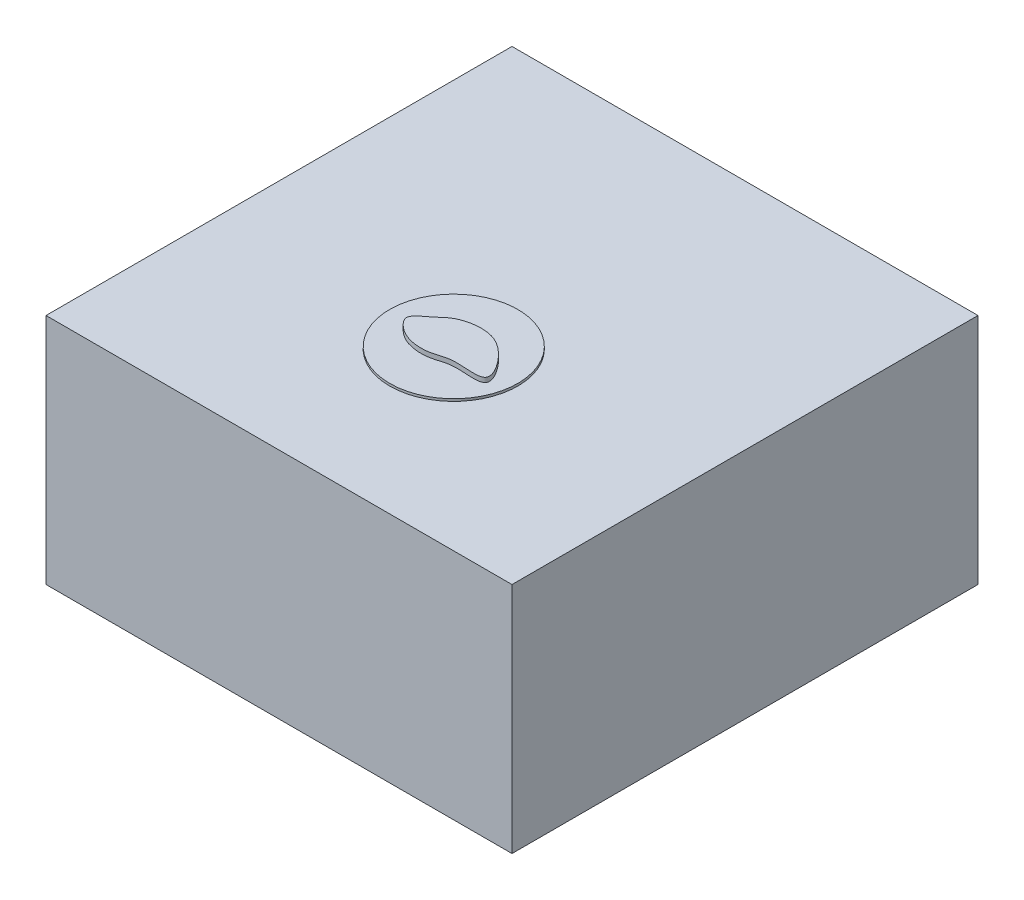
from build123d import *

# Parameters (mm, degrees)
SKETCH1_W             = 20
SKETCH1_H             = 10
BOSS_EXTRUDE1_DEPTH   = 20
SKETCH2_R             = 0.5
SKETCH5_R             = 2.75
BOSS_EXTRUDE4_DEPTH   = 0.1
SKETCH8_R             = 0.005
BOSS_EXTRUDE5_DEPTH   = 0.1
BOSS_EXTRUDE5_2_DEPTH = 0.1
BOSS_EXTRUDE5_3_DEPTH = 0.1
BOSS_EXTRUDE5_4_DEPTH = 0.1
BOSS_EXTRUDE5_5_DEPTH = 0.1
BOSS_EXTRUDE5_6_DEPTH = 0.1
BOSS_EXTRUDE5_7_DEPTH = 0.1
BOSS_EXTRUDE5_8_DEPTH = 0.1
BOSS_EXTRUDE5_9_DEPTH = 0.1
SLICE_2_DEPTH         = 0.3


with BuildPart() as part:
    # Sketch1 → Boss-Extrude1 (new body)
    with BuildSketch(Plane.XY):
        Rectangle(SKETCH1_W, SKETCH1_H)
    extrude(amount=BOSS_EXTRUDE1_DEPTH)


with BuildPart() as body_2:
    # ag/agcl electrodes: sweep along a path in Sketch3
    with BuildLine(Plane(origin=(7.5, 0, 0), x_dir=(0, 0, -1), z_dir=(1, 0, 0))) as ag_agcl_electrodes_path:
        Line((-20, 4), (-5, 4))
        ThreePointArc((-5, 4), (-4.292893219, 4.292893219), (-4, 5))
    # Sketch2 → ag/agcl electrodes (sweep)
    with BuildSketch(Plane.XY.offset(20)):
        with Locations((-7.5, 4)):
            Circle(SKETCH2_R)
        with Locations((7.5, 4)):
            Circle(SKETCH2_R)
    sweep(path=ag_agcl_electrodes_path.line)


with BuildPart() as body_3:
    # Sketch5 → Boss-Extrude4 (new body)
    with BuildSketch(Plane(origin=(0, 5, 0), x_dir=(1, 0, 0), z_dir=(0, 1, 0))):
        with Locations(Location((0, -12.5, 0), (0, 0, 270))):
            Circle(SKETCH5_R)
    extrude(amount=BOSS_EXTRUDE4_DEPTH)


with BuildPart() as body_4:
    # Sketch8 → Boss-Extrude5 (new body)
    with BuildSketch(Plane(origin=(0, 5.1, 0), x_dir=(-1, 0, 0), z_dir=(0, -1, 0))):
        with Locations(Location((0, -12.5, 0), (0, 0, 90))):
            Circle(SKETCH8_R)
    extrude(amount=BOSS_EXTRUDE5_DEPTH)


with BuildPart() as body_5:
    # Sketch8 → Boss-Extrude5 2 (new body)
    with BuildSketch(Plane(origin=(0, 5.1, 0), x_dir=(-1, 0, 0), z_dir=(0, -1, 0))):
        with Locations(Location((0.5, -12.5, 0), (0, 0, 90))):
            Circle(SKETCH8_R)
    extrude(amount=BOSS_EXTRUDE5_2_DEPTH)


with BuildPart() as body_6:
    # Sketch8 → Boss-Extrude5 3 (new body)
    with BuildSketch(Plane(origin=(0, 5.1, 0), x_dir=(-1, 0, 0), z_dir=(0, -1, 0))):
        with Locations(Location((0.5, -12, 0), (0, 0, 90))):
            Circle(SKETCH8_R)
    extrude(amount=BOSS_EXTRUDE5_3_DEPTH)


with BuildPart() as body_7:
    # Sketch8 → Boss-Extrude5 4 (new body)
    with BuildSketch(Plane(origin=(0, 5.1, 0), x_dir=(-1, 0, 0), z_dir=(0, -1, 0))):
        with Locations(Location((0, -12, 0), (0, 0, 90))):
            Circle(SKETCH8_R)
    extrude(amount=BOSS_EXTRUDE5_4_DEPTH)


with BuildPart() as body_8:
    # Sketch8 → Boss-Extrude5 5 (new body)
    with BuildSketch(Plane(origin=(0, 5.1, 0), x_dir=(-1, 0, 0), z_dir=(0, -1, 0))):
        with Locations(Location((0.5, -13, 0), (0, 0, 270))):
            Circle(SKETCH8_R)
    extrude(amount=BOSS_EXTRUDE5_5_DEPTH)


with BuildPart() as body_9:
    # Sketch8 → Boss-Extrude5 6 (new body)
    with BuildSketch(Plane(origin=(0, 5.1, 0), x_dir=(-1, 0, 0), z_dir=(0, -1, 0))):
        with Locations(Location((0, -13, 0), (0, 0, 270))):
            Circle(SKETCH8_R)
    extrude(amount=BOSS_EXTRUDE5_6_DEPTH)


with BuildPart() as body_10:
    # Sketch8 → Boss-Extrude5 7 (new body)
    with BuildSketch(Plane(origin=(0, 5.1, 0), x_dir=(-1, 0, 0), z_dir=(0, -1, 0))):
        with Locations(Location((-0.5, -13, 0), (0, 0, 90))):
            Circle(SKETCH8_R)
    extrude(amount=BOSS_EXTRUDE5_7_DEPTH)


with BuildPart() as body_11:
    # Sketch8 → Boss-Extrude5 8 (new body)
    with BuildSketch(Plane(origin=(0, 5.1, 0), x_dir=(-1, 0, 0), z_dir=(0, -1, 0))):
        with Locations(Location((-0.5, -12, 0), (0, 0, 270))):
            Circle(SKETCH8_R)
    extrude(amount=BOSS_EXTRUDE5_8_DEPTH)


with BuildPart() as body_12:
    # Sketch8 → Boss-Extrude5 9 (new body)
    with BuildSketch(Plane(origin=(0, 5.1, 0), x_dir=(-1, 0, 0), z_dir=(0, -1, 0))):
        with Locations(Location((-0.5, -12.5, 0), (0, 0, 270))):
            Circle(SKETCH8_R)
    extrude(amount=BOSS_EXTRUDE5_9_DEPTH)


with BuildPart() as body_13:
    # Sketch4 → slice 2 (new body)
    with BuildSketch(Plane(origin=(0, 5, 0), x_dir=(1, 0, 0), z_dir=(0, 1, 0))):
        with BuildLine():
            add(Edge.make_bspline(
                [(-1.329786825, -12.04709664), (-1.196342031, -11.939424685), (-0.824147777, -11.548957834), (0.251281573, -11.322574475), (1.372606671, -11.746573561), (2.652909809, -13.571837262), (0.780549472, -13.104467787), (-0.122057097, -13.506347246), (-0.994791107, -13.460960152), (-1.586432094, -13.116889112), (-2.086144249, -12.539169772), (-1.569499382, -12.240512354), (-1.329786825, -12.04709664)],
                knots=[0, 0, 0, 0, 0.049562645, 0.182817887, 0.303261475, 0.461561344, 0.613381106, 0.684437877, 0.79516613, 0.866564728, 0.910968514, 1, 1, 1, 1], degree=3))
        make_face()
    extrude(amount=SLICE_2_DEPTH)


solid = Compound([part.part, body_2.part, body_3.part, body_4.part, body_5.part, body_6.part, body_7.part, body_8.part, body_9.part, body_10.part, body_11.part, body_12.part, body_13.part])
